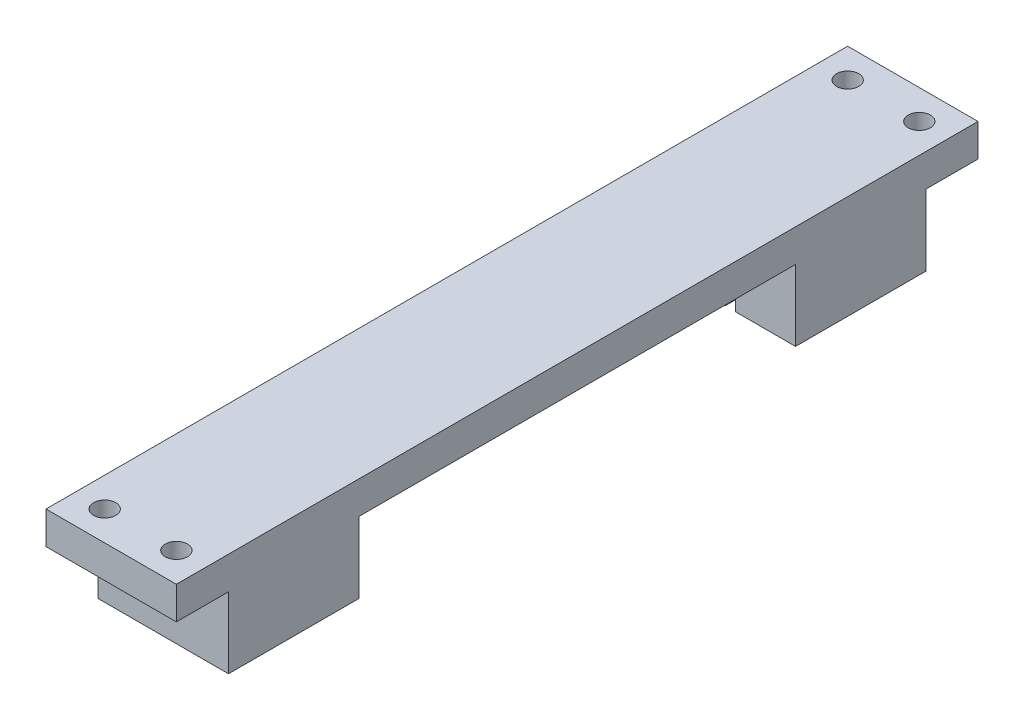
from build123d import *

# Parameters (mm, degrees)
SKETCH1_W            = 20
SKETCH1_H            = 28
BOSS_EXTRUDE1_DEPTH  = 5
SKETCH2_W            = 20
SKETCH2_H            = 20
BOSS_EXTRUDE2_DEPTH  = 10.9
SKETCH3_W            = 1.6
SKETCH3_H            = 15
CUT_EXTRUDE1_DEPTH   = 10.9
M3_CLEARANCE_HOLE1_D = 3.4
SKETCH6_W            = 20
SKETCH6_H            = 5
BOSS_EXTRUDE3_DEPTH  = 87
SKETCH7_W            = 20
SKETCH7_H            = 5
BOSS_EXTRUDE4_DEPTH  = 8
SKETCH8_W            = 20
SKETCH8_H            = 20
BOSS_EXTRUDE5_DEPTH  = 10.9
SKETCH9_W            = 1.6
SKETCH9_H            = 28.5
CUT_EXTRUDE2_DEPTH   = 10.9
M3_CLEARANCE_HOLE2_D = 3.4


with BuildPart() as part:
    # Sketch1 → Boss-Extrude1 (new body)
    with BuildSketch(Plane(origin=(0, 0, 0), x_dir=(1, 0, 0), z_dir=(0, 1, 0))):
        Rectangle(SKETCH1_W, SKETCH1_H)
    extrude(amount=BOSS_EXTRUDE1_DEPTH)

    # Sketch2 → Boss-Extrude2 (add)
    with BuildSketch(Plane(origin=(0, 0, 0), x_dir=(-1, 0, 0), z_dir=(0, -1, 0))):
        with Locations((0, 4)):
            Rectangle(SKETCH2_W, SKETCH2_H)
    extrude(amount=BOSS_EXTRUDE2_DEPTH)

    # Sketch3 → Cut-Extrude1 (cut)
    with BuildSketch(Plane(origin=(0, -10.9, 0), x_dir=(-1, 0, 0), z_dir=(0, -1, 0))):
        with Locations((0, 6.5)):
            Rectangle(SKETCH3_W, SKETCH3_H)
    extrude(amount=-CUT_EXTRUDE1_DEPTH, mode=Mode.SUBTRACT)

    # M3 Clearance Hole1 (through all)
    with Locations(Plane(origin=(0, 0, 0), x_dir=(-1, 0, 0), z_dir=(0, -1, 0))):
        with Locations((-5.5, -9.5), (5.5, -9.5)):
            Hole(M3_CLEARANCE_HOLE1_D / 2)

    # Sketch6 → Boss-Extrude3 (add)
    with BuildSketch(Plane(origin=(0, 0, -14), x_dir=(-1, 0, 0), z_dir=(0, 0, -1))):
        with Locations((0, 2.5)):
            Rectangle(SKETCH6_W, SKETCH6_H)
    extrude(amount=BOSS_EXTRUDE3_DEPTH)

    # Sketch7 → Boss-Extrude4 (add)
    with BuildSketch(Plane(origin=(0, 0, -101), x_dir=(-1, 0, 0), z_dir=(0, 0, -1))):
        with Locations((0, 2.5)):
            Rectangle(SKETCH7_W, SKETCH7_H)
    extrude(amount=BOSS_EXTRUDE4_DEPTH)

    # Sketch8 → Boss-Extrude5 (add)
    with BuildSketch(Plane(origin=(0, 0, 0), x_dir=(-1, 0, 0), z_dir=(0, -1, 0))):
        with Locations((0, 91)):
            Rectangle(SKETCH8_W, SKETCH8_H)
    extrude(amount=BOSS_EXTRUDE5_DEPTH)

    # Sketch9 → Cut-Extrude2 (cut)
    with BuildSketch(Plane(origin=(0, -10.9, 0), x_dir=(-1, 0, 0), z_dir=(0, -1, 0))):
        with Locations((0, 74.25)):
            Rectangle(SKETCH9_W, SKETCH9_H)
    extrude(amount=-CUT_EXTRUDE2_DEPTH, mode=Mode.SUBTRACT)

    # M3 Clearance Hole2 (through all)
    with Locations(Plane(origin=(0, 0, 0), x_dir=(-1, 0, 0), z_dir=(0, -1, 0))):
        with Locations((-5.5, 104.5), (5.5, 104.5)):
            Hole(M3_CLEARANCE_HOLE2_D / 2)


solid = part.part
